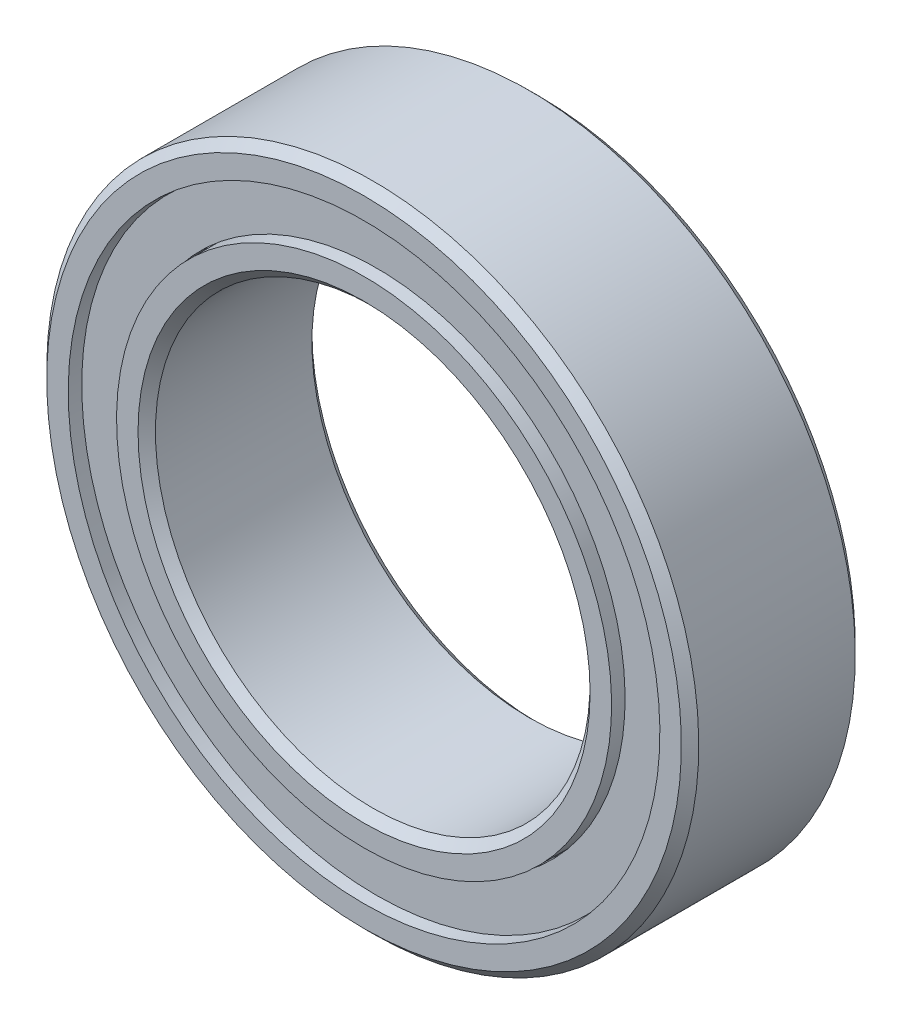
from build123d import *

# Parameters (mm, degrees)
SKETCH5_W         = 0.381
SKETCH5_H         = 1.060311112
CIRPATTERN1_COUNT = 11


with BuildPart() as part:
    # Sketch5 → Revolve1 (revolve)
    with BuildSketch(Plane(origin=(0, 0, 0), x_dir=(0, 0, -1), z_dir=(1, 0, 0))):
        with BuildLine():
            Line((1.8, 7.5), (-1.8, 7.5))
            Line((-1.8, 7.5), (-2, 7.3))
            Line((-2, 7.3), (-2, 6.805555556))
            Line((-2, 6.805555556), (-0.888888889, 6.805555556))
            ThreePointArc((-0.888888889, 6.805555556), (0, 7.298220126), (0.888888889, 6.805555556))
            Line((0.888888889, 6.805555556), (2, 6.805555556))
            Line((2, 6.805555556), (2, 7.3))
            Line((2, 7.3), (1.8, 7.5))
        make_face()
        with Locations((1.524110063, 6.25)):
            Rectangle(SKETCH5_W, SKETCH5_H)
        with Locations((-1.524110063, 6.25)):
            Rectangle(SKETCH5_W, SKETCH5_H)
    revolve(axis=Axis((0, 0, 2), (0, 0, -1)))


with BuildPart() as body_2:
    # Sketch3 → Revolve3 (revolve)
    with BuildSketch(Plane(origin=(0, 0, 0), x_dir=(0, 0, -1), z_dir=(1, 0, 0))):
        with BuildLine():
            Line((-2, 5.694444444), (-0.888888889, 5.694444444))
            ThreePointArc((-0.888888889, 5.694444444), (0, 5.201779874), (0.888888889, 5.694444444))
            Line((0.888888889, 5.694444444), (2, 5.694444444))
            Line((2, 5.694444444), (2, 5.2))
            Line((2, 5.2), (1.8, 5))
            Line((1.8, 5), (-1.8, 5))
            Line((-1.8, 5), (-2, 5.2))
            Line((-2, 5.2), (-2, 5.694444444))
        make_face()
    revolve(axis=Axis((0, 0, 2), (0, 0, -1)))


with BuildPart() as body_3:
    # Sketch4 → Revolve4 (revolve)
    with BuildSketch(Plane(origin=(0, 0, 0), x_dir=(0, 0, -1), z_dir=(1, 0, 0))):
        with BuildLine():
            Line((-1.048220126, 6.25), (1.048220126, 6.25))
            ThreePointArc((1.048220126, 6.25), (0, 7.298220126), (-1.048220126, 6.25))
        make_face()
    revolve(axis=Axis((0, 6.25, 1.048220126), (0, 0, -1)))


with BuildPart() as cirpattern1_1:
    # CirPattern1: pattern copy
    add(body_3.part.rotate(Axis((0, 0, 0), (0, 0, 1)), 1 * 360 / CIRPATTERN1_COUNT))


with BuildPart() as cirpattern1_2:
    # CirPattern1: pattern copy
    add(body_3.part.rotate(Axis((0, 0, 0), (0, 0, 1)), 2 * 360 / CIRPATTERN1_COUNT))


with BuildPart() as cirpattern1_3:
    # CirPattern1: pattern copy
    add(body_3.part.rotate(Axis((0, 0, 0), (0, 0, 1)), 3 * 360 / CIRPATTERN1_COUNT))


with BuildPart() as cirpattern1_4:
    # CirPattern1: pattern copy
    add(body_3.part.rotate(Axis((0, 0, 0), (0, 0, 1)), 4 * 360 / CIRPATTERN1_COUNT))


with BuildPart() as cirpattern1_5:
    # CirPattern1: pattern copy
    add(body_3.part.rotate(Axis((0, 0, 0), (0, 0, 1)), 5 * 360 / CIRPATTERN1_COUNT))


with BuildPart() as cirpattern1_6:
    # CirPattern1: pattern copy
    add(body_3.part.rotate(Axis((0, 0, 0), (0, 0, 1)), 6 * 360 / CIRPATTERN1_COUNT))


with BuildPart() as cirpattern1_7:
    # CirPattern1: pattern copy
    add(body_3.part.rotate(Axis((0, 0, 0), (0, 0, 1)), 7 * 360 / CIRPATTERN1_COUNT))


with BuildPart() as cirpattern1_8:
    # CirPattern1: pattern copy
    add(body_3.part.rotate(Axis((0, 0, 0), (0, 0, 1)), 8 * 360 / CIRPATTERN1_COUNT))


with BuildPart() as cirpattern1_9:
    # CirPattern1: pattern copy
    add(body_3.part.rotate(Axis((0, 0, 0), (0, 0, 1)), 9 * 360 / CIRPATTERN1_COUNT))


with BuildPart() as cirpattern1_10:
    # CirPattern1: pattern copy
    add(body_3.part.rotate(Axis((0, 0, 0), (0, 0, 1)), 10 * 360 / CIRPATTERN1_COUNT))


solid = Compound([part.part, body_2.part, body_3.part, cirpattern1_1.part, cirpattern1_2.part, cirpattern1_3.part, cirpattern1_4.part, cirpattern1_5.part, cirpattern1_6.part, cirpattern1_7.part, cirpattern1_8.part, cirpattern1_9.part, cirpattern1_10.part])
